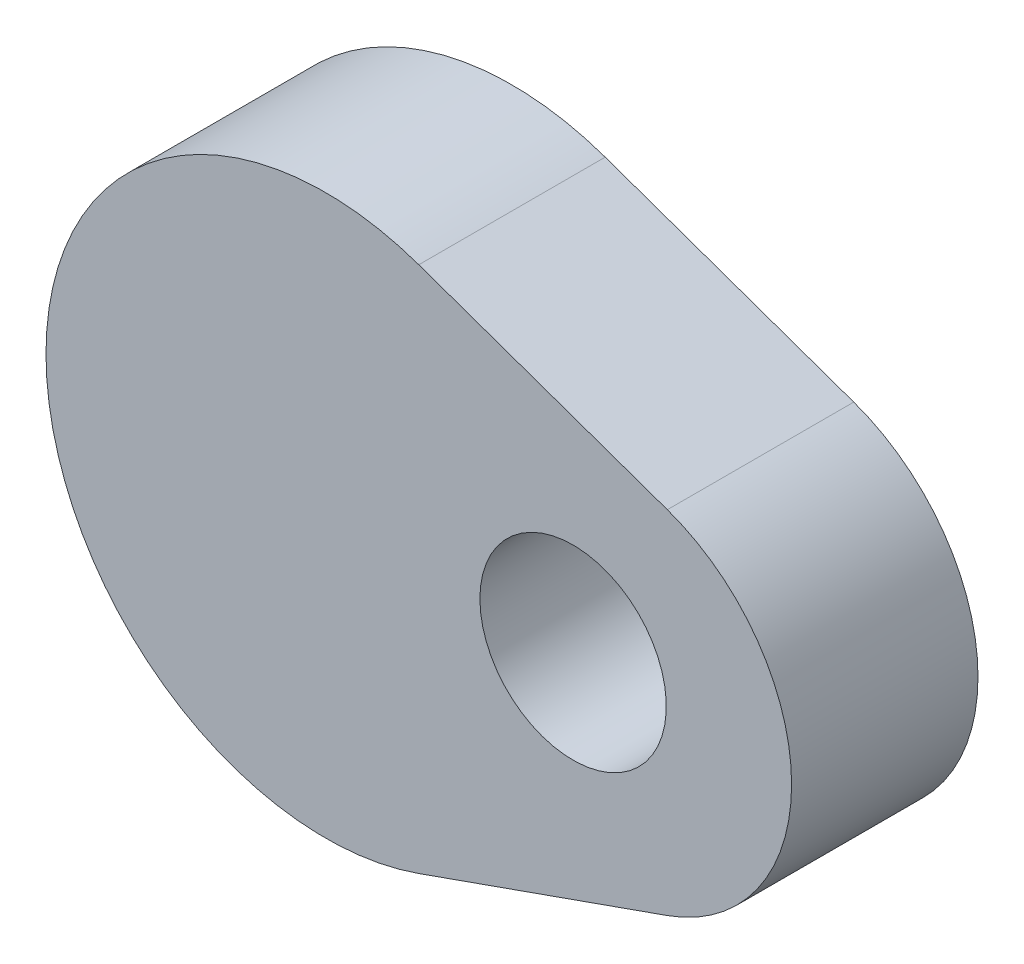
from build123d import *

# Parameters (mm, degrees)
EXTRUDE_1_DEPTH     = 10
SKETCH_3_R          = 5
CUT_EXTRUDE_1_DEPTH = 11


with BuildPart() as part:
    # 草图1 → 凸台-拉伸1 (new body)
    with BuildSketch(Plane.XY):
        with BuildLine():
            Line((5, 14.142135624), (18.333333333, 9.428090416))
            ThreePointArc((18.333333333, 9.428090416), (25, 0), (18.333333333, -9.428090416))
            Line((18.333333333, -9.428090416), (5, -14.142135624))
            ThreePointArc((5, -14.142135624), (-15, 0), (5, 14.142135624))
        make_face()
    extrude(amount=EXTRUDE_1_DEPTH)

    # 草图3 → 切除-拉伸1 (cut, through all)
    with BuildSketch(Plane(origin=(0, 0, 0), x_dir=(-1, 0, 0), z_dir=(0, 0, -1))):
        with Locations((-13.277262402, 0.262881409)):
            Circle(SKETCH_3_R)
    extrude(amount=-CUT_EXTRUDE_1_DEPTH, mode=Mode.SUBTRACT)


solid = part.part
